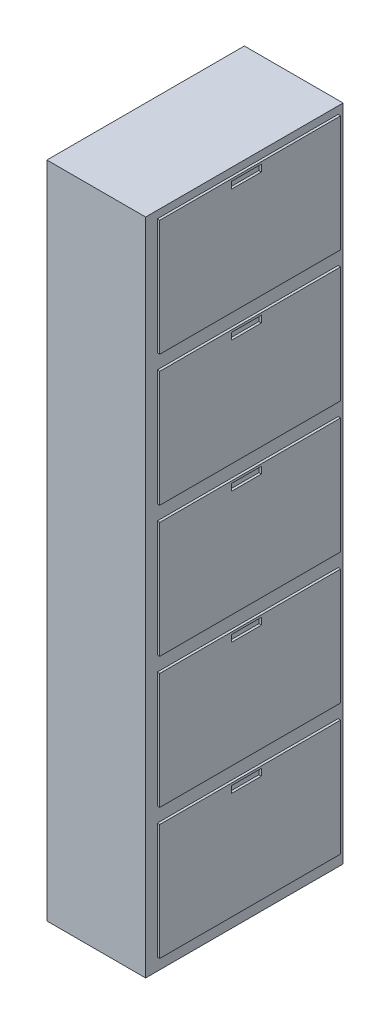
from build123d import *

# Parameters (mm, degrees)
SKETCH1_W           = 400
SKETCH1_H           = 2670
BOSS_EXTRUDE1_DEPTH = 800
SKETCH3_W           = 732.835133331
SKETCH3_H           = 470
SKETCH3_W_2         = 121.072841775
SKETCH3_H_2         = 27.505181151
BOSS_EXTRUDE3_DEPTH = 10


with BuildPart() as part:
    # Sketch1 → Boss-Extrude1 (new body)
    with BuildSketch(Plane.XY):
        with Locations((63.061970043, 2844.986327315)):
            Rectangle(SKETCH1_W, SKETCH1_H)
    extrude(amount=BOSS_EXTRUDE1_DEPTH)

    # Sketch3 → Boss-Extrude3 (add)
    with BuildSketch(Plane(origin=(263.061970043, 0, 0), x_dir=(0, 0, -1), z_dir=(1, 0, 0))):
        with Locations((-386.417566666, 2324.986327315)):
            Rectangle(SKETCH3_W, SKETCH3_H)
        with Locations((-401.761491339, 2537.407960532)):
            Rectangle(SKETCH3_W_2, SKETCH3_H_2, mode=Mode.SUBTRACT)
        with Locations((-386.417566666, 1794.986327315)):
            Rectangle(SKETCH3_W, SKETCH3_H)
        with Locations((-401.761491339, 2007.407960532)):
            Rectangle(SKETCH3_W_2, SKETCH3_H_2, mode=Mode.SUBTRACT)
        with Locations((-386.417566666, 2854.986327315)):
            Rectangle(SKETCH3_W, SKETCH3_H)
        with Locations((-401.761491339, 3067.407960532)):
            Rectangle(SKETCH3_W_2, SKETCH3_H_2, mode=Mode.SUBTRACT)
        with Locations((-386.417566666, 3384.986327315)):
            Rectangle(SKETCH3_W, SKETCH3_H)
        with Locations((-401.761491339, 3597.407960532)):
            Rectangle(SKETCH3_W_2, SKETCH3_H_2, mode=Mode.SUBTRACT)
        with Locations((-386.417566666, 3914.986327315)):
            Rectangle(SKETCH3_W, SKETCH3_H)
        with Locations((-401.761491339, 4127.407960532)):
            Rectangle(SKETCH3_W_2, SKETCH3_H_2, mode=Mode.SUBTRACT)
    extrude(amount=BOSS_EXTRUDE3_DEPTH)


solid = part.part
